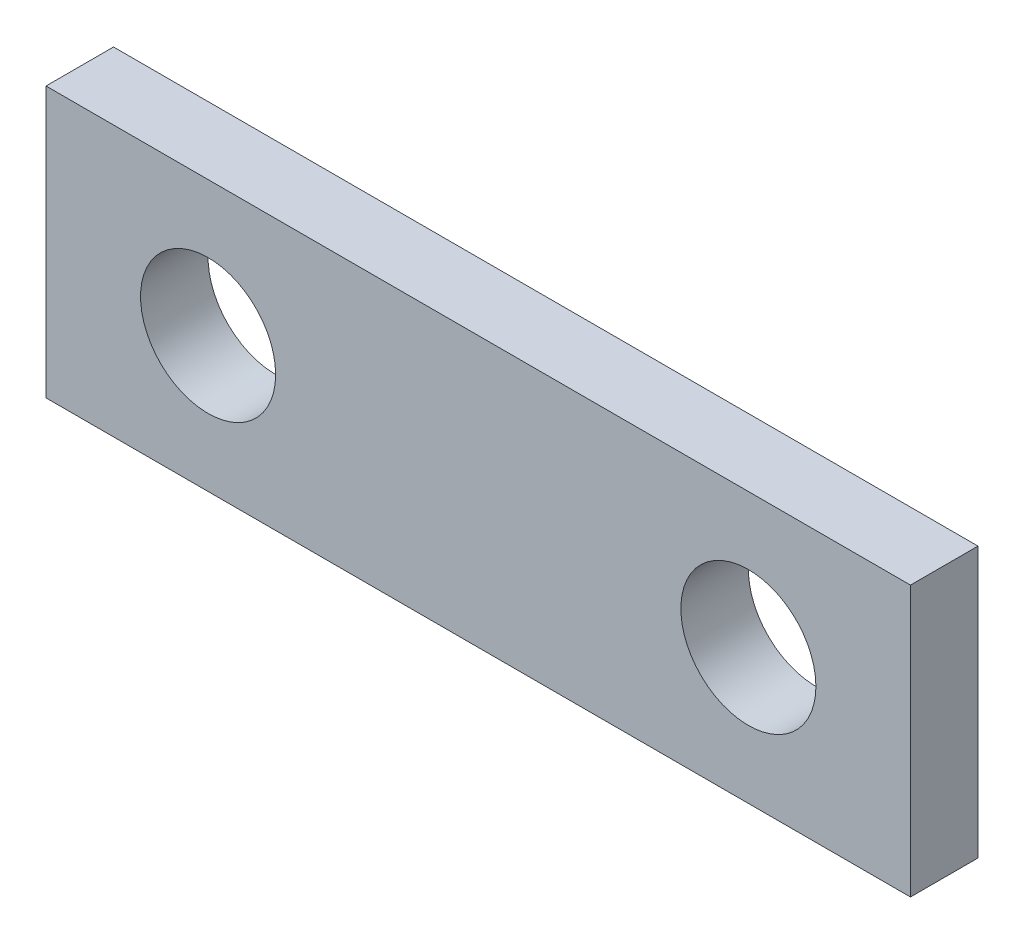
from build123d import *

# Parameters (mm, degrees)
SKETCH1_W           = 20.32
SKETCH1_H           = 6.35
SKETCH1_R           = 1.5875
BOSS_EXTRUDE1_DEPTH = 1.5875


with BuildPart() as part:
    # Sketch1 → Boss-Extrude1 (new body)
    with BuildSketch(Plane.XY):
        with Locations((10.16, 3.175)):
            Rectangle(SKETCH1_W, SKETCH1_H)
        with Locations((3.81, 3.175)):
            Circle(SKETCH1_R, mode=Mode.SUBTRACT)
        with Locations((16.51, 3.175)):
            Circle(SKETCH1_R, mode=Mode.SUBTRACT)
    extrude(amount=BOSS_EXTRUDE1_DEPTH)


solid = part.part
